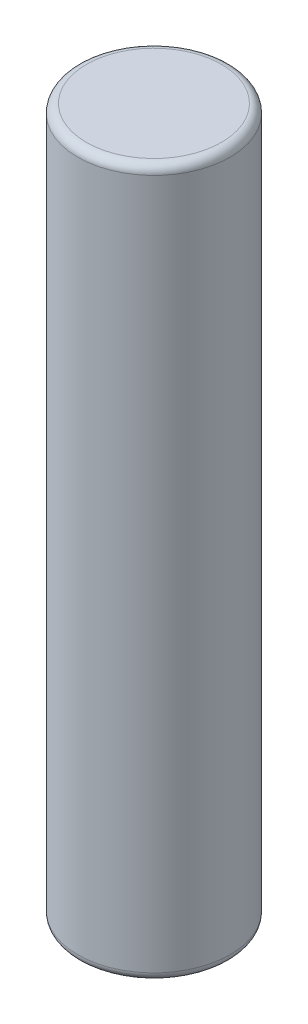
from build123d import *

# Parameters (mm, degrees)
SKETCH1_R           = 1.775
BOSS_EXTRUDE1_DEPTH = 16.5
FILLET1_R           = 0.2


with BuildPart() as part:
    # Sketch1 → Boss-Extrude1 (new body)
    with BuildSketch(Plane(origin=(0, 0, 0), x_dir=(1, 0, 0), z_dir=(0, 1, 0))):
        Circle(SKETCH1_R)
    extrude(amount=BOSS_EXTRUDE1_DEPTH)

    # Fillet1
    fillet1_edges = [part.edges().sort_by_distance(p)[0] for p in [
        (-1.775, 0, 0),
        (-1.775, 16.5, 0),
    ]]
    fillet(fillet1_edges, radius=FILLET1_R)


solid = part.part
